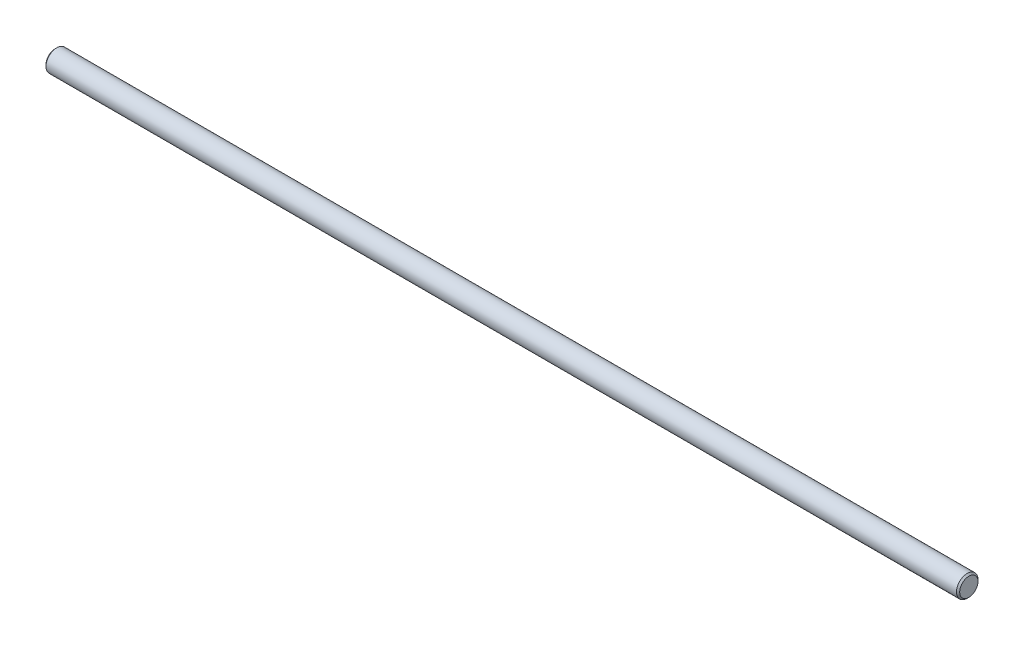
from build123d import *

# Parameters (mm, degrees)
SKETCH2_R                = 3.96875
BOSS_EXTRUDE1_DEPTH      = 168.275
BOSS_EXTRUDE1_DEPTH_BACK = 168.275
CHAMFER1_SIZE            = 0.5953125


with BuildPart() as part:
    # Sketch2 → Boss-Extrude1 (new body, two sides)
    with BuildSketch(Plane(origin=(0, 0, 0), x_dir=(0, 0, -1), z_dir=(1, 0, 0))) as boss_extrude1_sk:
        Circle(SKETCH2_R)
    extrude(amount=BOSS_EXTRUDE1_DEPTH)
    extrude(boss_extrude1_sk.sketch, amount=-BOSS_EXTRUDE1_DEPTH_BACK)

    # Chamfer1
    chamfer1_edges = [part.edges().sort_by_distance(p)[0] for p in [
        (-168.275, 0, 3.96875),
        (168.275, 0, 3.96875),
    ]]
    chamfer(chamfer1_edges, length=CHAMFER1_SIZE)


solid = part.part
